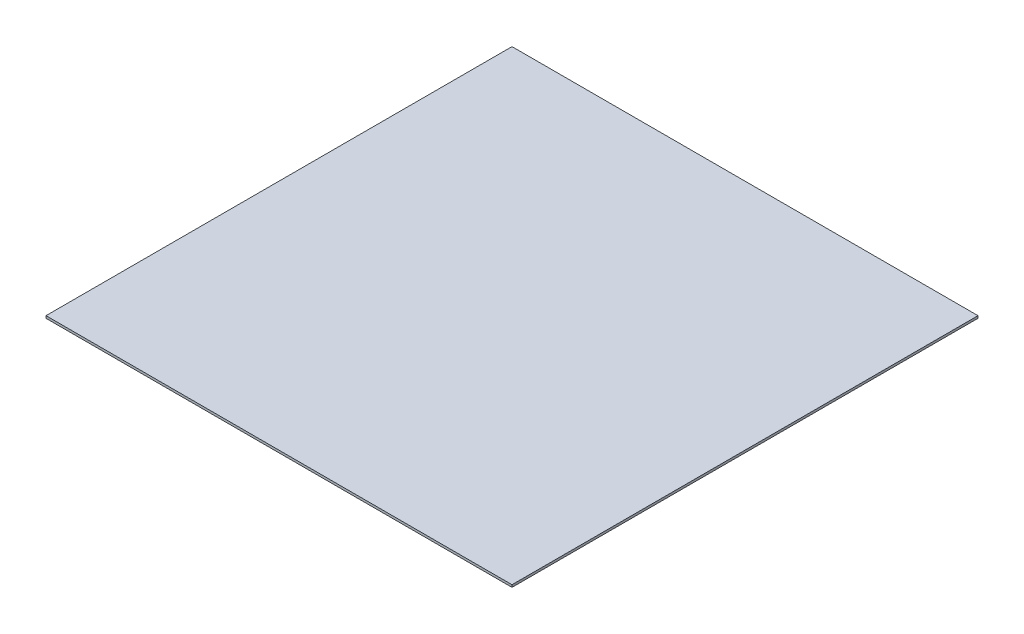
from build123d import *

# Parameters (mm, degrees)
SKETCH1_W           = 2000
SKETCH1_H           = 2000
BOSS_EXTRUDE1_DEPTH = 10


with BuildPart() as part:
    # Sketch1 → Boss-Extrude1 (new body)
    with BuildSketch(Plane(origin=(0, 0, 0), x_dir=(1, 0, 0), z_dir=(0, 1, 0))):
        Rectangle(SKETCH1_W, SKETCH1_H)
    extrude(amount=BOSS_EXTRUDE1_DEPTH)


solid = part.part
